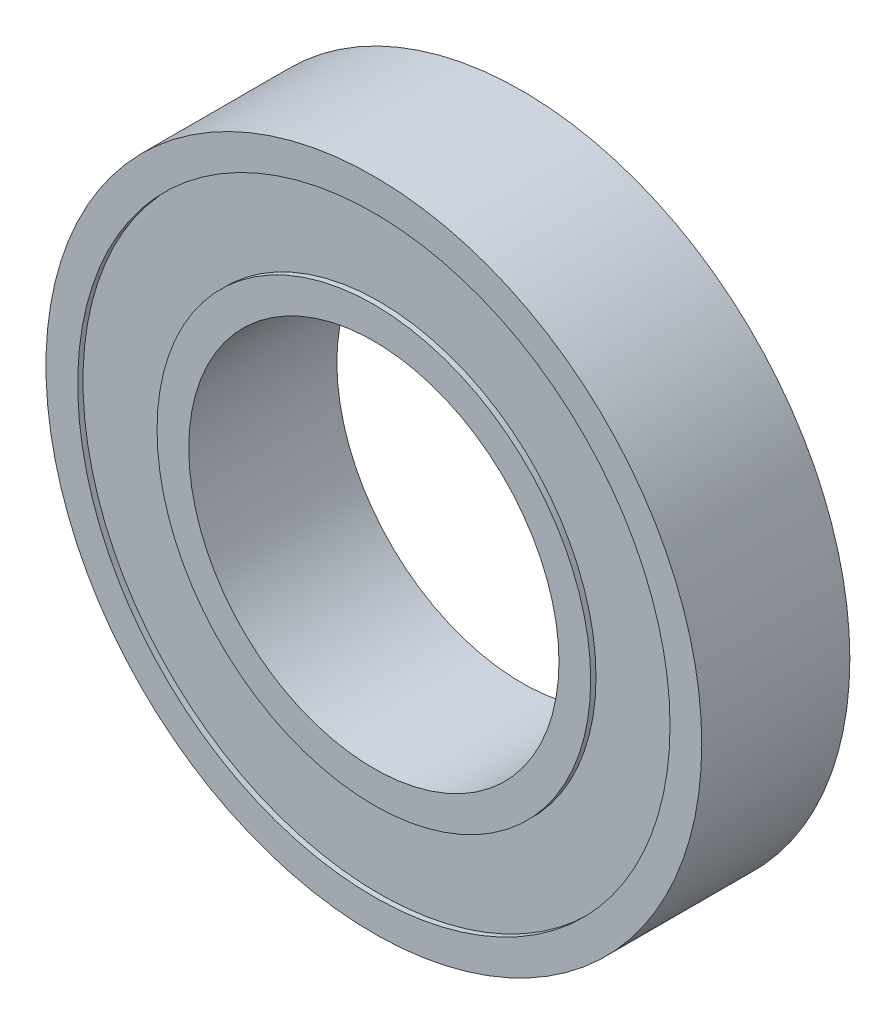
from build123d import *

# Parameters (mm, degrees)
SKETCH1_R             = 31
SKETCH1_R_2           = 28
BOSS_EXTRUDE1_DEPTH   = 14
SKETCH1_R_3           = 20.5
SKETCH1_R_4           = 17.5
BOSS_EXTRUDE1_2_DEPTH = 14
BOSS_EXTRUDE2_START   = 0.5
SKETCH1_3_R           = 28
SKETCH1_3_R_2         = 20.5
BOSS_EXTRUDE2_DEPTH   = 13


with BuildPart() as part:
    # Sketch1 → Boss-Extrude1 (new body)
    with BuildSketch(Plane(origin=(0, 0, 0), x_dir=(0, 1, 0), z_dir=(0, 0, 1))):
        Circle(SKETCH1_R)
        Circle(SKETCH1_R_2, mode=Mode.SUBTRACT)
    extrude(amount=BOSS_EXTRUDE1_DEPTH)



with BuildPart() as body_2:
    # Sketch1 → Boss-Extrude1 2 (new body)
    with BuildSketch(Plane(origin=(0, 0, 0), x_dir=(0, 1, 0), z_dir=(0, 0, 1))):
        Circle(SKETCH1_R_3)
        Circle(SKETCH1_R_4, mode=Mode.SUBTRACT)
    extrude(amount=BOSS_EXTRUDE1_2_DEPTH)


with BuildPart() as part_1:
    add(part.part)

    add(body_2.part)  # Boss-Extrude2 merges body 2
    # Sketch1_3 → Boss-Extrude2 (add)
    with BuildSketch(Plane(origin=(0, 0, 0), x_dir=(0, 1, 0), z_dir=(0, 0, 1)).offset(BOSS_EXTRUDE2_START)):
        Circle(SKETCH1_3_R)
        Circle(SKETCH1_3_R_2, mode=Mode.SUBTRACT)
    extrude(amount=BOSS_EXTRUDE2_DEPTH)


solid = part_1.part
